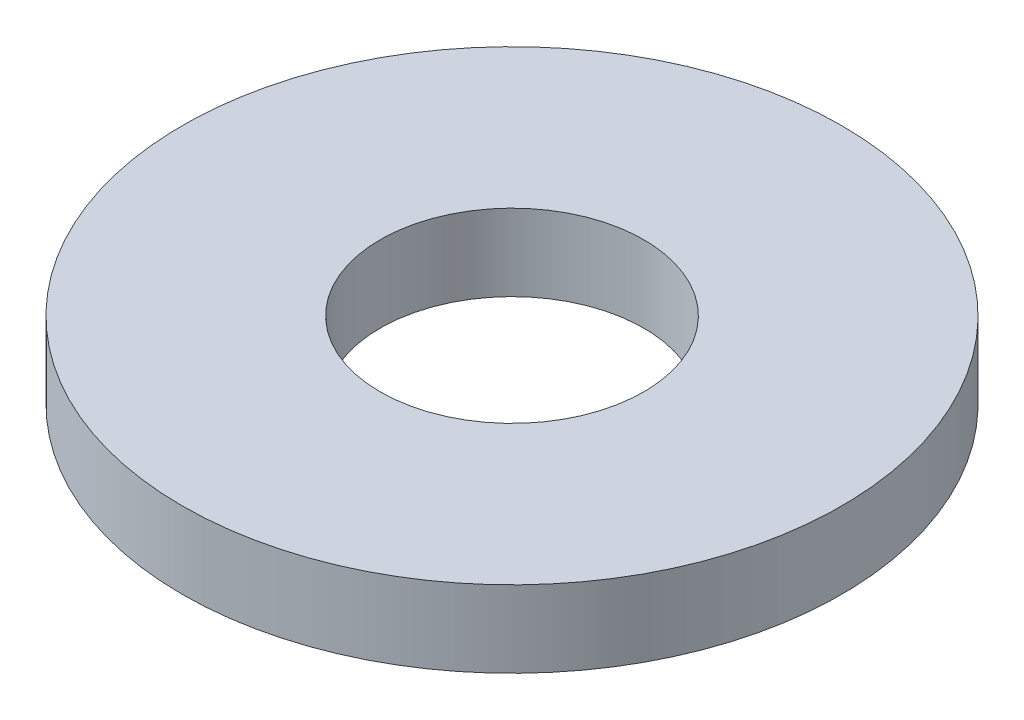
from build123d import *

# Parameters (mm, degrees)
SKETCH1_R           = 4
SKETCH1_R_2         = 1.6
BOSS_EXTRUDE1_DEPTH = 0.93


with BuildPart() as part:
    # Sketch1 → Boss-Extrude1 (new body)
    with BuildSketch(Plane(origin=(0, 0, 0), x_dir=(1, 0, 0), z_dir=(0, 1, 0))):
        with Locations(Location((0, 0, 0), (0, 0, 270))):  # turned: the seam where the file's is
            Circle(SKETCH1_R)
        with Locations(Location((0, 0, 0), (0, 0, 270))):  # turned: the seam where the file's is
            Circle(SKETCH1_R_2, mode=Mode.SUBTRACT)
    extrude(amount=BOSS_EXTRUDE1_DEPTH)


solid = part.part
